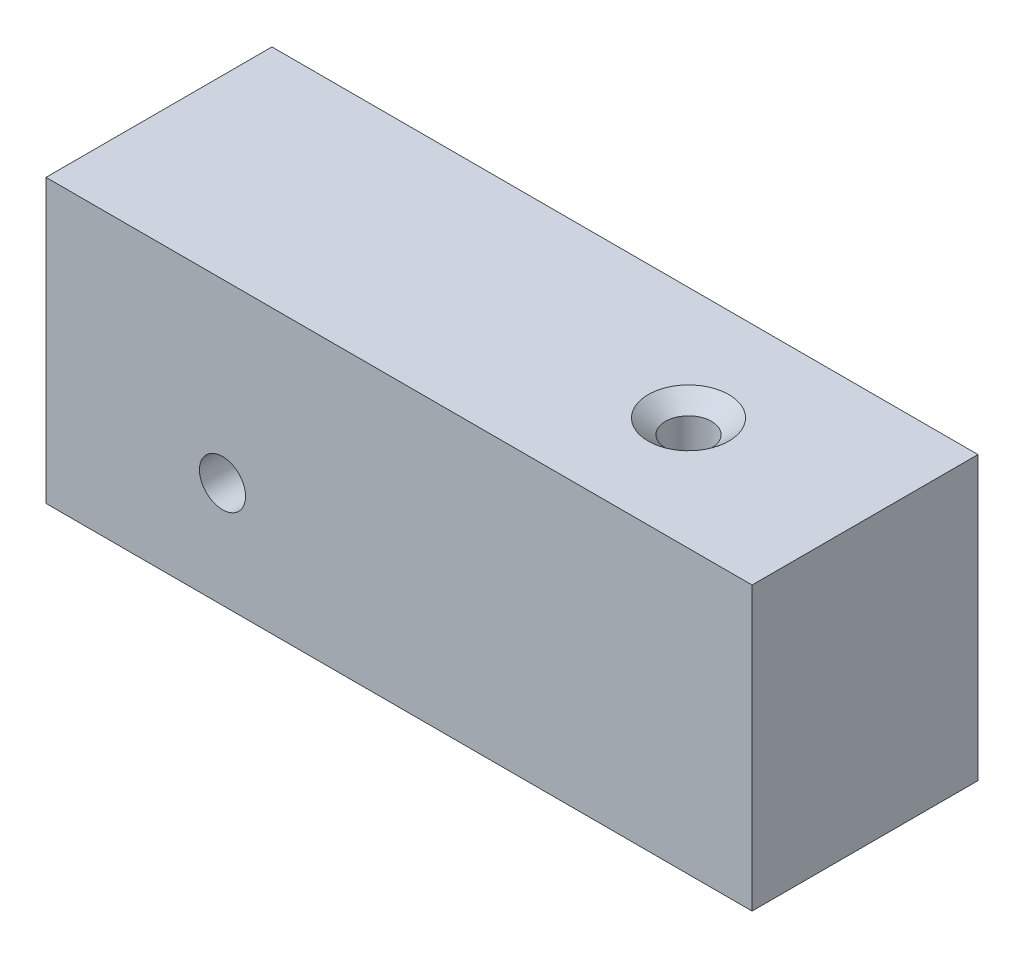
from build123d import *

# Parameters (mm, degrees)
SKETCH1_W                                         = 50
SKETCH1_H                                         = 20
BOSS_EXTRUDE1_DEPTH                               = 16
CSK_FOR_4_FLAT_HEAD_MACHINE_SCREW_100_D           = 3.2639
CSK_FOR_4_FLAT_HEAD_MACHINE_SCREW_100_DEPTH       = 16
CSK_FOR_4_FLAT_HEAD_MACHINE_SCREW_100_CSINK_D     = 5.715
CSK_FOR_4_FLAT_HEAD_MACHINE_SCREW_100_CSINK_ANGLE = 100
CSK_FOR_4_FLAT_HEAD_MACHINE_SCREW_2_D             = 3.2639
CSK_FOR_4_FLAT_HEAD_MACHINE_SCREW_2_DEPTH         = 20
CSK_FOR_4_FLAT_HEAD_MACHINE_SCREW_2_CSINK_D       = 5.715
CSK_FOR_4_FLAT_HEAD_MACHINE_SCREW_2_CSINK_ANGLE   = 100


with BuildPart() as part:
    # Sketch1 → Boss-Extrude1 (new body)
    with BuildSketch(Plane.XY):
        Rectangle(SKETCH1_W, SKETCH1_H)
    extrude(amount=-BOSS_EXTRUDE1_DEPTH)

    # CSK for _4 Flat Head Machine Screw _100
    with Locations(Plane(origin=(-12.5, -2.5, -16), x_dir=(-1, 0, 0), z_dir=(0, 0, -1))):
        with Locations((0, 0)):
            CounterSinkHole(CSK_FOR_4_FLAT_HEAD_MACHINE_SCREW_100_D / 2, CSK_FOR_4_FLAT_HEAD_MACHINE_SCREW_100_CSINK_D / 2, depth=CSK_FOR_4_FLAT_HEAD_MACHINE_SCREW_100_DEPTH, counter_sink_angle=CSK_FOR_4_FLAT_HEAD_MACHINE_SCREW_100_CSINK_ANGLE)

    # CSK for _4 Flat Head Machine Screw _ 2
    with Locations(Plane(origin=(0, 10, 0), x_dir=(1, 0, 0), z_dir=(0, 1, 0))):
        with Locations((12.5, 8)):
            CounterSinkHole(CSK_FOR_4_FLAT_HEAD_MACHINE_SCREW_2_D / 2, CSK_FOR_4_FLAT_HEAD_MACHINE_SCREW_2_CSINK_D / 2, depth=CSK_FOR_4_FLAT_HEAD_MACHINE_SCREW_2_DEPTH, counter_sink_angle=CSK_FOR_4_FLAT_HEAD_MACHINE_SCREW_2_CSINK_ANGLE)


solid = part.part
